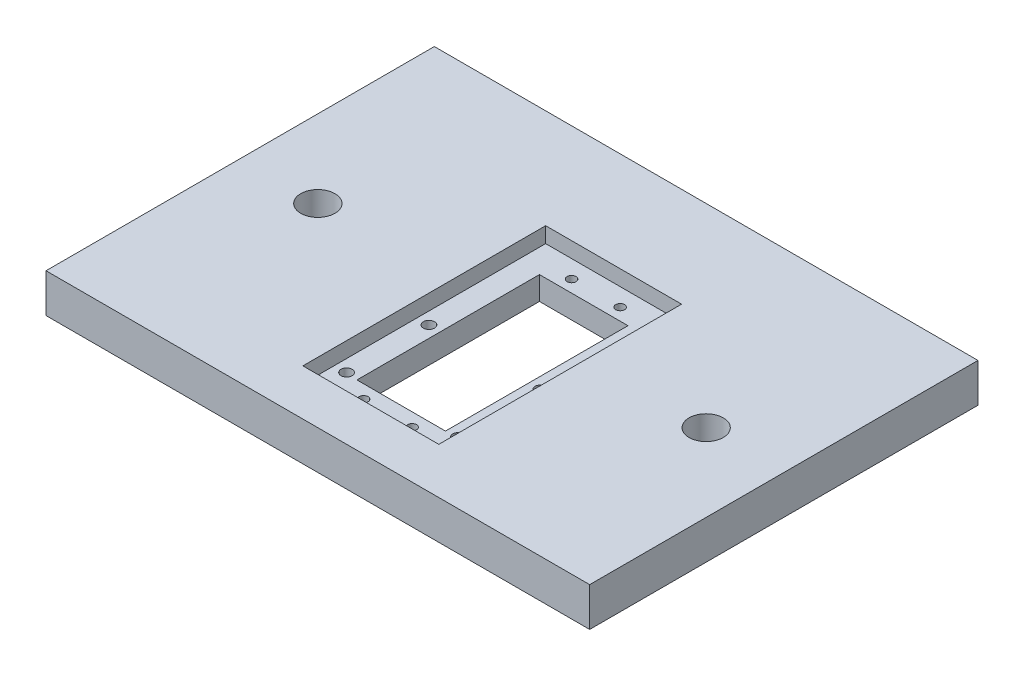
from build123d import *

# Parameters (mm, degrees)
SKETCH1_W           = 177.8
SKETCH1_H           = 127
SKETCH1_R           = 5.588
SKETCH1_R_2         = 1.8288
SKETCH1_R_3         = 1.4605
SKETCH1_W_2         = 28.956
SKETCH1_H_2         = 59.69
BOSS_EXTRUDE1_DEPTH = 12.7
SKETCH2_W           = 44.45
SKETCH2_H           = 79.4004
CUT_EXTRUDE1_DEPTH  = 5.08


with BuildPart() as part:
    # Sketch1 → Boss-Extrude1 (new body)
    with BuildSketch(Plane(origin=(0, 0, 0), x_dir=(1, 0, 0), z_dir=(0, 1, 0))):
        Rectangle(SKETCH1_W, SKETCH1_H)
        with Locations((-63.5, 0)):
            Circle(SKETCH1_R, mode=Mode.SUBTRACT)
        with Locations((63.5, 0)):
            Circle(SKETCH1_R, mode=Mode.SUBTRACT)
        with Locations((20.557934463, -38.085909964)):
            Circle(SKETCH1_R_2, mode=Mode.SUBTRACT)
        with Locations((-16.018065537, -38.085909964)):
            Circle(SKETCH1_R_2, mode=Mode.SUBTRACT)
        with Locations((-16.018065537, -11.145141601)):
            Circle(SKETCH1_R_2, mode=Mode.SUBTRACT)
        with Locations((20.557934463, -11.145141601)):
            Circle(SKETCH1_R_2, mode=Mode.SUBTRACT)
        with Locations((-5.667565537, -42.871775783)):
            Circle(SKETCH1_R_3, mode=Mode.SUBTRACT)
        with Locations((10.207434463, -42.871775783)):
            Circle(SKETCH1_R_3, mode=Mode.SUBTRACT)
        with Locations((-5.667565537, 25.149424217)):
            Circle(SKETCH1_R_3, mode=Mode.SUBTRACT)
        with Locations((10.207434463, 25.149424217)):
            Circle(SKETCH1_R_3, mode=Mode.SUBTRACT)
        with Locations((2.269934463, -8.661150783)):
            Rectangle(SKETCH1_W_2, SKETCH1_H_2, mode=Mode.SUBTRACT)
    extrude(amount=BOSS_EXTRUDE1_DEPTH)

    # Sketch2 → Cut-Extrude1 (cut)
    with BuildSketch(Plane(origin=(0, 12.7, 0), x_dir=(1, 0, 0), z_dir=(0, 1, 0))):
        with Locations((2.269934463, -8.737350783)):
            Rectangle(SKETCH2_W, SKETCH2_H)
    extrude(amount=-CUT_EXTRUDE1_DEPTH, mode=Mode.SUBTRACT)


solid = part.part
